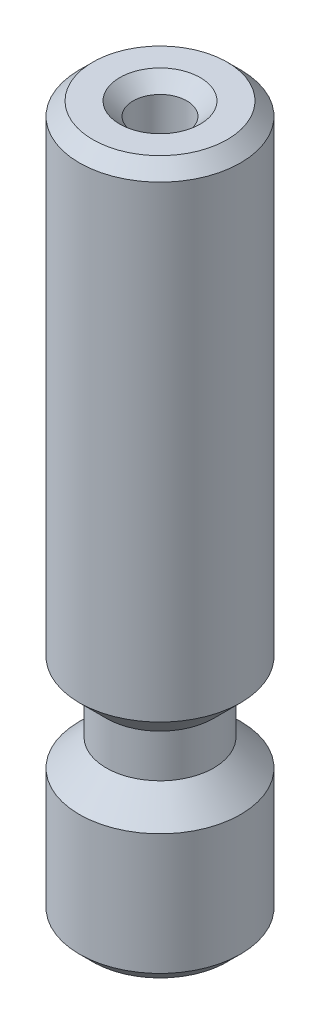
from build123d import *

# Parameters (mm, degrees)
CHAMFER2_SIZE = 0.5


with BuildPart() as part:
    # Sketch4 → Revolve1 (revolve)
    with BuildSketch(Plane.XY):
        Polygon((-1, 0), (-1, 26.5), (-3, 26.5), (-3, 8.6), (-2, 7.6), (-2, 6), (-3, 5), (-3, 0), align=None)
    revolve(axis=Axis((0, -1000, 0), (0, 1, 0)))

    # Chamfer2
    chamfer2_edges = [part.edges().sort_by_distance(p)[0] for p in [
        (3, 0, 0),
        (3, 26.5, 0),
        (1, 26.5, 0),
    ]]
    chamfer(chamfer2_edges, length=CHAMFER2_SIZE)


solid = part.part
